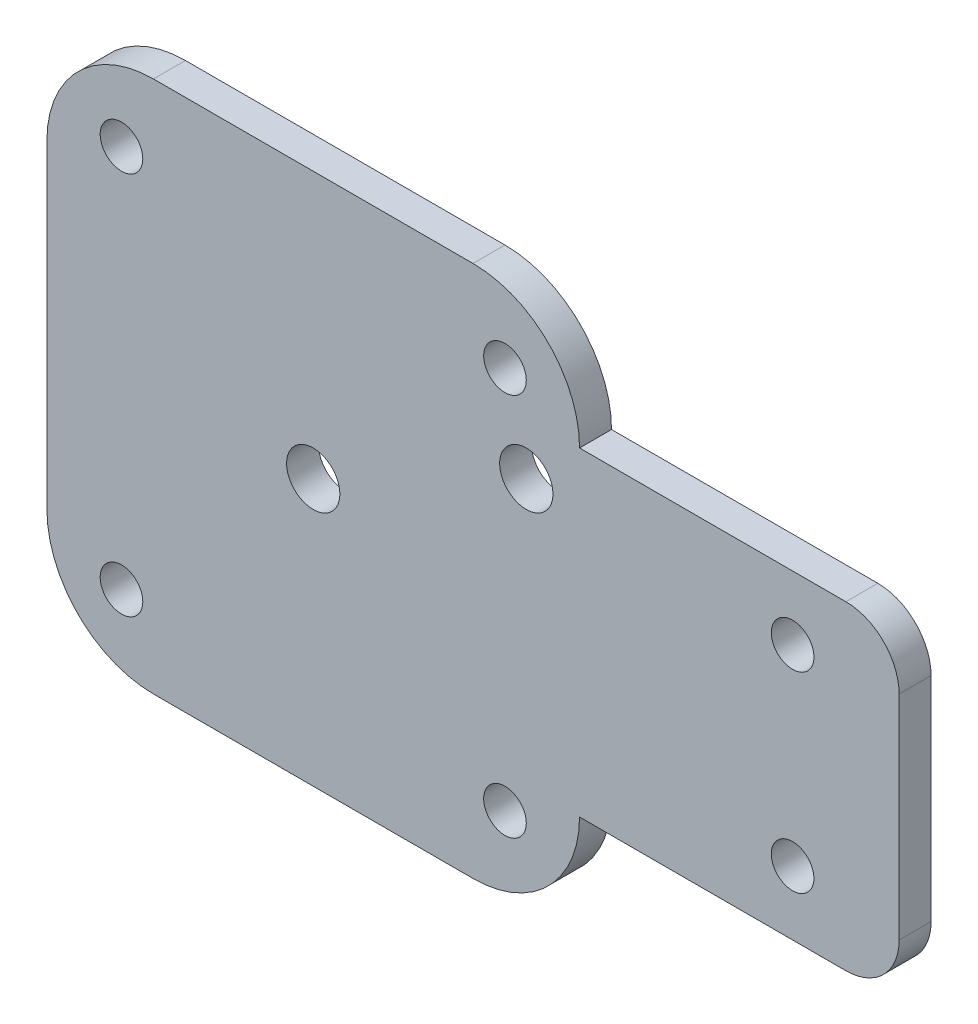
from build123d import *

# Parameters (mm, degrees)
CROQUIS1_R              = 2.5
CROQUIS1_R_2            = 2
SALIENTE_EXTRUIR1_DEPTH = 3


with BuildPart() as part:
    # Croquis1 → Saliente-Extruir1 (new body)
    with BuildSketch(Plane.XY):
        with BuildLine():
            ThreePointArc((0, 40), (2.928932188, 47.071067812), (10, 50))
            Line((10, 50), (40, 50))
            ThreePointArc((40, 50), (47.071067812, 47.071067812), (50, 40))
            Line((50, 40), (50, 10))
            ThreePointArc((50, 10), (47.071067812, 2.928932188), (40, 0))
            Line((40, 0), (10, 0))
            ThreePointArc((10, 0), (2.928932188, 2.928932188), (0, 10))
            Line((0, 10), (0, 40))
        make_face()
        with Locations((45, 35)):
            Circle(CROQUIS1_R, mode=Mode.SUBTRACT)
        with Locations((25, 25)):
            Circle(CROQUIS1_R, mode=Mode.SUBTRACT)
        with Locations((43, 43)):
            Circle(CROQUIS1_R_2, mode=Mode.SUBTRACT)
        with Locations((7, 43)):
            Circle(CROQUIS1_R_2, mode=Mode.SUBTRACT)
        with Locations((43, 7)):
            Circle(CROQUIS1_R_2, mode=Mode.SUBTRACT)
        with Locations((7, 7)):
            Circle(CROQUIS1_R_2, mode=Mode.SUBTRACT)
        with BuildLine():
            ThreePointArc((75, 40), (78.535533906, 38.535533906), (80, 35))
            Line((80, 35), (80, 15))
            ThreePointArc((80, 15), (78.535533906, 11.464466094), (75, 10))
            Line((75, 10), (50, 10))
            Line((50, 10), (50, 40))
            Line((50, 40), (75, 40))
        make_face()
        with Locations((70, 16)):
            Circle(CROQUIS1_R_2, mode=Mode.SUBTRACT)
        with Locations((70, 34)):
            Circle(CROQUIS1_R_2, mode=Mode.SUBTRACT)
    extrude(amount=SALIENTE_EXTRUIR1_DEPTH)


solid = part.part
